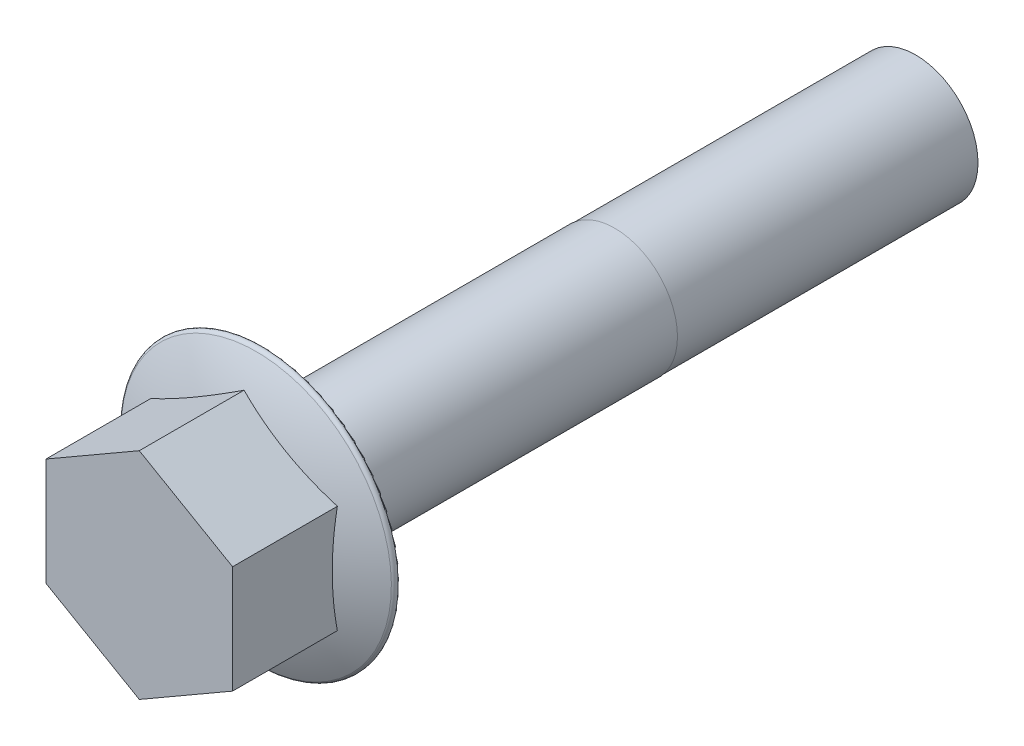
from build123d import *

# Parameters (mm, degrees)
HEAD_DEPTH     = 15.748
SHANK_SKETCH_R = 7.9375
SHANK_DEPTH    = 82.55
THREAD_END_W   = 38.1
THREAD_END_H   = 0.05


with BuildPart() as part:
    # Head Sketch → Head (new body)
    with BuildSketch(Plane.XY):
        Polygon((0, 13.638168059), (11.811, 6.819084029), (11.811, -6.819084029), (0, -13.638168059), (-11.811, -6.819084029), (-11.811, 6.819084029), align=None)
    extrude(amount=HEAD_DEPTH)

    # Shank Sketch → Shank (add)
    with BuildSketch(Plane.XY):
        Circle(SHANK_SKETCH_R)
    extrude(amount=-SHANK_DEPTH)

    # Sketch3 → Flange (revolve)
    with BuildSketch(Plane(origin=(0, 0, 0), x_dir=(-1, 0, 0), z_dir=(0, 1, 0))):
        with BuildLine():
            Line((-16.891, 0), (0, 0))
            Line((0, 0), (0, 5))
            ThreePointArc((0, 5), (-8.794301894, 3.972903196), (-17.115237243, 0.946897817))
            ThreePointArc((-17.115237243, 0.946897817), (-17.377543373, 0.384780446), (-16.891, 0))
        make_face()
    revolve(axis=Axis((0, 0, 0), (0, 0, 1)))

    # Thread End → Thread Cut (revolve, cut)
    with BuildSketch(Plane(origin=(0, 0, 0), x_dir=(0, 0, -1), z_dir=(1, 0, 0))):
        with Locations((63.5, 7.9125)):
            Rectangle(THREAD_END_W, THREAD_END_H)
    revolve(axis=Axis((0, 0, -21.551935625), (0, 0, -1)), mode=Mode.SUBTRACT)


solid = part.part
